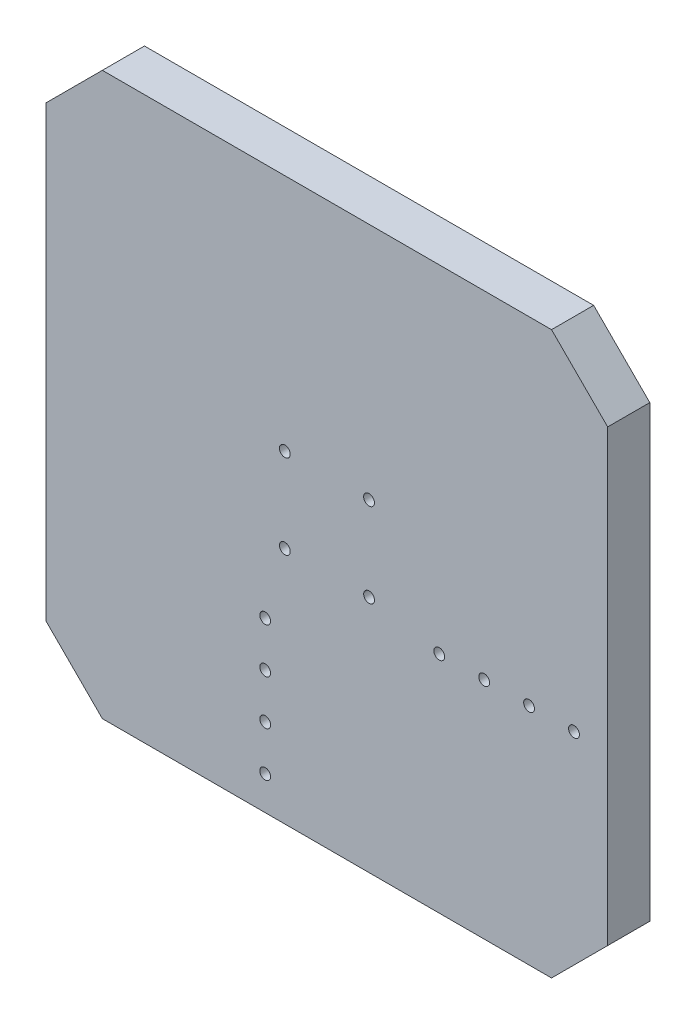
from build123d import *

# Parameters (mm, degrees)
SKETCH2_W           = 200
SKETCH2_H           = 200
BOSS_EXTRUDE1_DEPTH = 15
CHAMFER1_SIZE       = 20
SKETCH3_R           = 1.925
CUT_EXTRUDE1_DEPTH  = 16
SKETCH4_R           = 1.925
CUT_EXTRUDE2_DEPTH  = 16
SKETCH5_R           = 1.925
CUT_EXTRUDE3_DEPTH  = 16


with BuildPart() as part:
    # Sketch2 → Boss-Extrude1 (new body)
    with BuildSketch(Plane.XY):
        Rectangle(SKETCH2_W, SKETCH2_H)
    extrude(amount=BOSS_EXTRUDE1_DEPTH)

    # Chamfer1
    chamfer1_edges = [part.edges().sort_by_distance(p)[0] for p in [
        (100, -100, 7.5),
        (-100, -100, 7.5),
        (-100, 100, 7.5),
        (100, 100, 7.5),
    ]]
    chamfer(chamfer1_edges, length=CHAMFER1_SIZE)

    # Sketch3 → Cut-Extrude1 (cut, through all)
    with BuildSketch(Plane.XY.offset(15)):
        with Locations((-22, -88)):
            Circle(SKETCH3_R)
        with Locations((-22, -72)):
            Circle(SKETCH3_R)
        with Locations((-22, -56)):
            Circle(SKETCH3_R)
        with Locations((-22, -40)):
            Circle(SKETCH3_R)
    extrude(amount=-CUT_EXTRUDE1_DEPTH, mode=Mode.SUBTRACT)

    # Sketch4 → Cut-Extrude2 (cut, through all)
    with BuildSketch(Plane.XY.offset(15)):
        with Locations((88, -20)):
            Circle(SKETCH4_R)
        with Locations((72, -20)):
            Circle(SKETCH4_R)
        with Locations((56, -20)):
            Circle(SKETCH4_R)
        with Locations((40, -20)):
            Circle(SKETCH4_R)
    extrude(amount=-CUT_EXTRUDE2_DEPTH, mode=Mode.SUBTRACT)

    # Sketch5 → Cut-Extrude3 (cut, through all)
    with BuildSketch(Plane.XY.offset(15)):
        with Locations((15, 15)):
            Circle(SKETCH5_R)
        with Locations((15, -15)):
            Circle(SKETCH5_R)
        with Locations((-15, -15)):
            Circle(SKETCH5_R)
        with Locations((-15, 15)):
            Circle(SKETCH5_R)
    extrude(amount=-CUT_EXTRUDE3_DEPTH, mode=Mode.SUBTRACT)


solid = part.part
